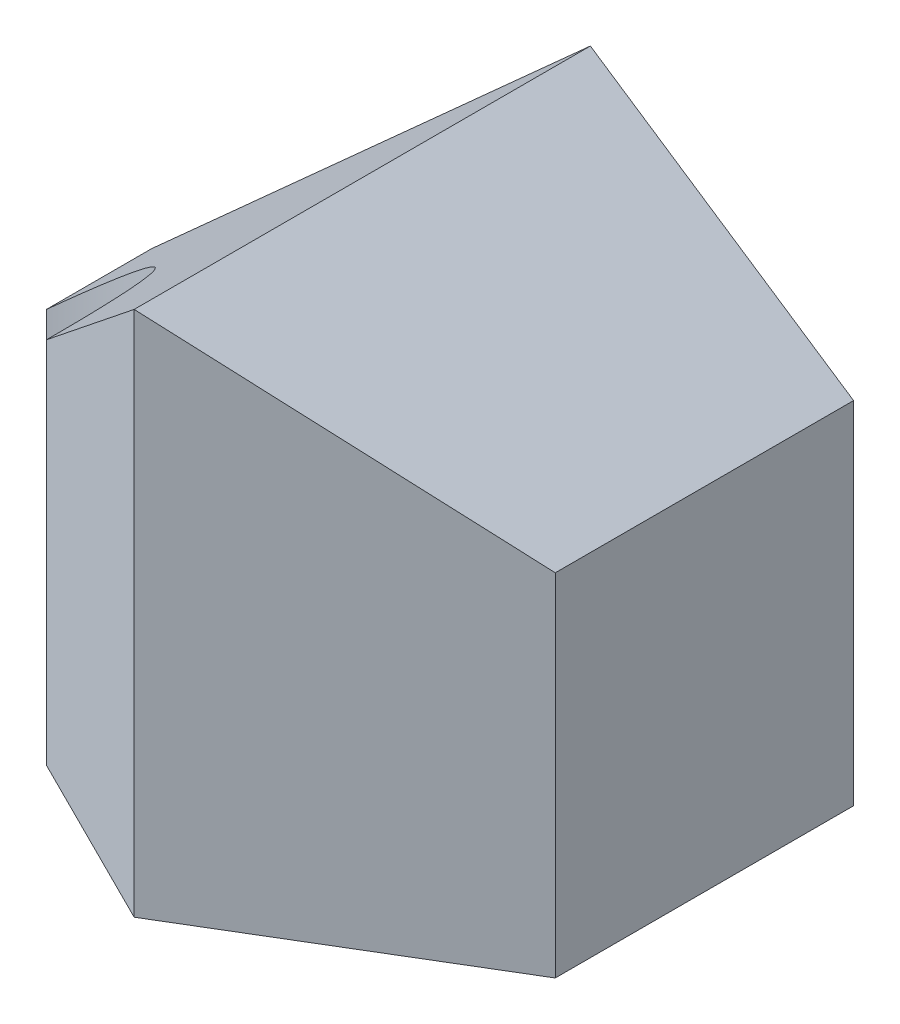
from build123d import *

# Parameters (mm, degrees)
EXTRUDE1_DEPTH     = 60
CUT_EXTRUDE1_DEPTH = 53


with BuildPart() as part:
    # Sketch1 → Extrude1 (new body)
    with BuildSketch(Plane(origin=(0, 0, 0), x_dir=(1, 0, 0), z_dir=(0, 1, 0))):
        with BuildLine():
            Line((0, 40), (0, 52))
            Line((0, 52), (80, 52))
            Line((80, 52), (80, 18))
            Line((80, 18), (50, 0))
            Line((50, 0), (30, 10))
            ThreePointArc((30, 10), (21.213203436, 31.213203436), (0, 40))
        make_face()
    extrude(amount=EXTRUDE1_DEPTH)

    # Sketch2 → Cut-Extrude1 (cut, through all)
    with BuildSketch(Plane.XY):
        Polygon((0, 60), (0, 15), (50, 60), align=None)
        Polygon((80, 40), (80, 60), (50, 60), align=None)
    extrude(amount=-CUT_EXTRUDE1_DEPTH, mode=Mode.SUBTRACT)


solid = part.part
